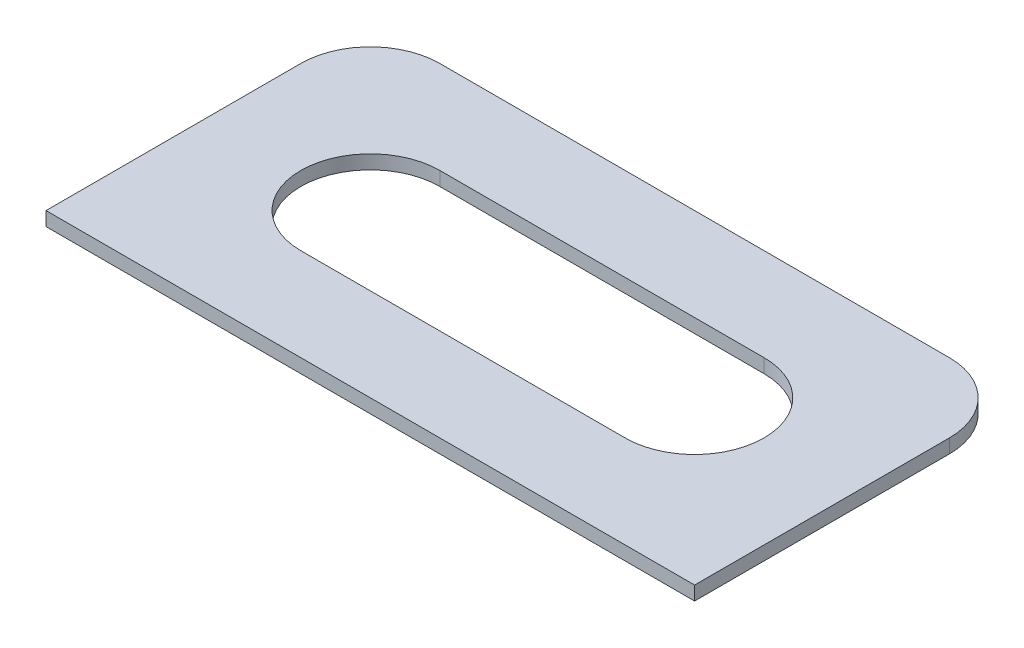
from build123d import *

# Parameters (mm, degrees)
BOSS_EXTRU_1_DEPTH = 3


with BuildPart() as part:
    # Esquisse3 → Boss.-Extru.1 (new body)
    with BuildSketch(Plane(origin=(0, 0, 0), x_dir=(1, 0, 0), z_dir=(0, 1, 0))):
        with BuildLine():
            Line((-65, 21.652023134), (45, 21.652023134))
            ThreePointArc((45, 21.652023134), (55.606601718, 17.258624852), (60, 6.652023134))
            Line((60, 6.652023134), (60, -48.347976866))
            Line((60, -48.347976866), (-80, -48.347976866))
            Line((-80, -48.347976866), (-80, 6.652023134))
            ThreePointArc((-80, 6.652023134), (-75.606601718, 17.258624852), (-65, 21.652023134))
        make_face()
        with BuildLine():
            Line((-45, 1.652023134), (25, 1.652023134))
            ThreePointArc((25, 1.652023134), (40, -13.347976866), (25, -28.347976866))
            Line((25, -28.347976866), (-45, -28.347976866))
            ThreePointArc((-45, -28.347976866), (-60, -13.347976866), (-45, 1.652023134))
        make_face(mode=Mode.SUBTRACT)
    extrude(amount=BOSS_EXTRU_1_DEPTH)


solid = part.part
